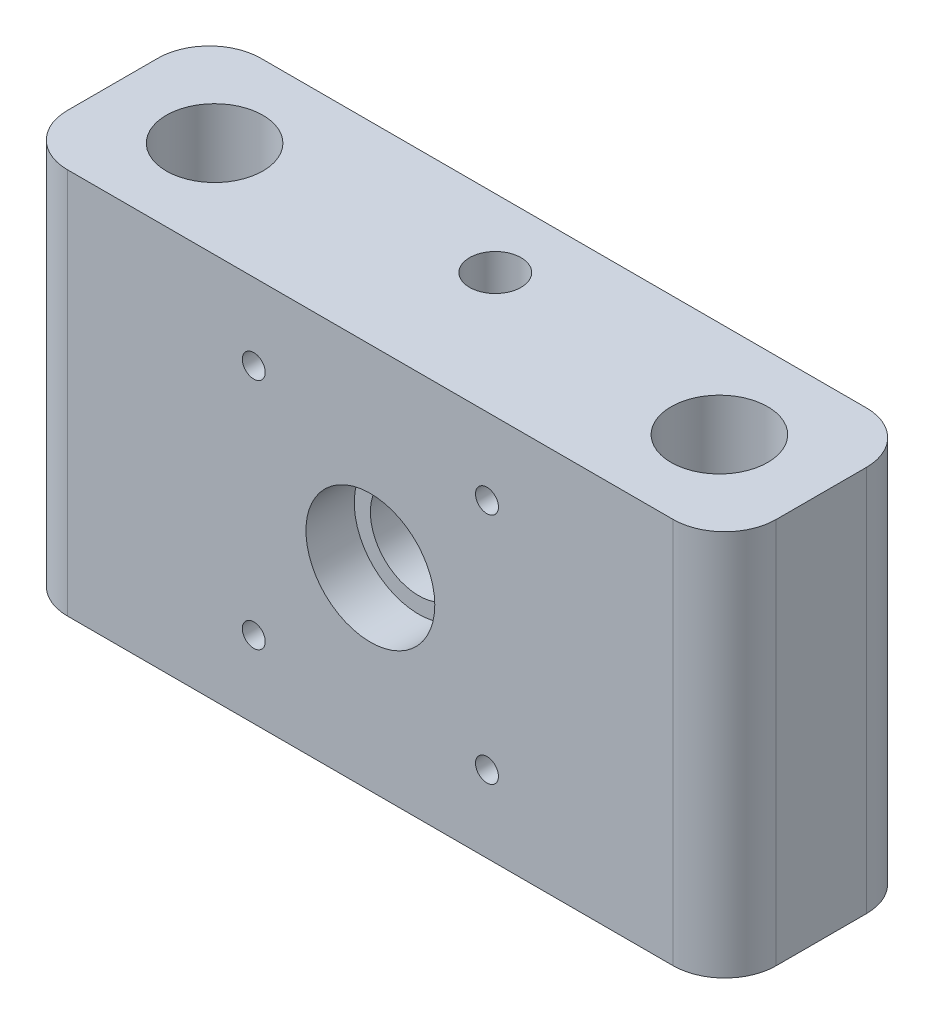
from build123d import *

# Parameters (mm, degrees)
SKETCH1_W           = 69.85
SKETCH1_H           = 38.1
BOSS_EXTRUDE1_DEPTH = 9.525
SKETCH2_R           = 6.35
CUT_EXTRUDE1_DEPTH  = 4.7625
SKETCH3_R           = 4.7625
CUT_EXTRUDE2_DEPTH  = 20.05
SKETCH4_R           = 1.1303
CUT_EXTRUDE3_DEPTH  = 20.05
SKETCH6_R           = 3.175
CUT_EXTRUDE4_DEPTH  = 39.1
SKETCH7_R           = 4.7625
CUT_EXTRUDE5_DEPTH  = 28.575
SKETCH8_R           = 2.54
CUT_EXTRUDE6_DEPTH  = 9.652
FILLET1_R           = 5.08


with BuildPart() as part:
    # Sketch1 → Boss-Extrude1 (new body, symmetric)
    with BuildSketch(Plane.XY):
        with Locations((34.925, 19.05)):
            Rectangle(SKETCH1_W, SKETCH1_H)
    extrude(amount=BOSS_EXTRUDE1_DEPTH, both=True)

    # Sketch2 → Cut-Extrude1 (cut)
    with BuildSketch(Plane.XY.offset(9.525)):
        with Locations((34.925, 19.05)):
            Circle(SKETCH2_R)
    extrude(amount=-CUT_EXTRUDE1_DEPTH, mode=Mode.SUBTRACT)

    # Sketch3 → Cut-Extrude2 (cut, through all)
    with BuildSketch(Plane.XY.offset(9.525)):
        with Locations((34.925, 19.05)):
            Circle(SKETCH3_R)
    extrude(amount=-CUT_EXTRUDE2_DEPTH, mode=Mode.SUBTRACT)

    # Sketch4 → Cut-Extrude3 (cut, through all)
    with BuildSketch(Plane.XY.offset(9.525)):
        with Locations((23.4315, 30.5435)):
            Circle(SKETCH4_R)
        with Locations((46.4185, 30.5435)):
            Circle(SKETCH4_R)
        with Locations((46.4185, 7.5565)):
            Circle(SKETCH4_R)
        with Locations((23.4315, 7.5565)):
            Circle(SKETCH4_R)
    extrude(amount=-CUT_EXTRUDE3_DEPTH, mode=Mode.SUBTRACT)

    # Sketch6 → Cut-Extrude4 (cut, through all)
    with BuildSketch(Plane(origin=(0, 38.1, 0), x_dir=(1, 0, 0), z_dir=(0, 1, 0))):
        with Locations((10.045078415, 0)):
            Circle(SKETCH6_R)
    cut_extrude4 = extrude(amount=-CUT_EXTRUDE4_DEPTH, mode=Mode.SUBTRACT)

    # Sketch7 → Cut-Extrude5 (cut)
    with BuildSketch(Plane(origin=(0, 38.1, 0), x_dir=(1, 0, 0), z_dir=(0, 1, 0))):
        with Locations((10.045078415, 0)):
            Circle(SKETCH7_R)
    cut_extrude5 = extrude(amount=-CUT_EXTRUDE5_DEPTH, mode=Mode.SUBTRACT)

    # Mirror1: Cut-Extrude4, Cut-Extrude5 across plane
    add(cut_extrude4.mirror(Plane.ZY.offset(-34.925)), mode=Mode.SUBTRACT)
    add(cut_extrude5.mirror(Plane.ZY.offset(-34.925)), mode=Mode.SUBTRACT)

    # Sketch8 → Cut-Extrude6 (cut)
    with BuildSketch(Plane(origin=(0, 38.1, 0), x_dir=(1, 0, 0), z_dir=(0, 1, 0))):
        with Locations((34.925, 2.788579275)):
            Circle(SKETCH8_R)
    extrude(amount=-CUT_EXTRUDE6_DEPTH, mode=Mode.SUBTRACT)

    # Fillet1
    fillet1_edges = [part.edges().sort_by_distance(p)[0] for p in [
        (69.85, 19.05, 9.525),
        (0, 19.05, 9.525),
        (69.85, 19.05, -9.525),
        (0, 19.05, -9.525),
    ]]
    fillet(fillet1_edges, radius=FILLET1_R)


solid = part.part
